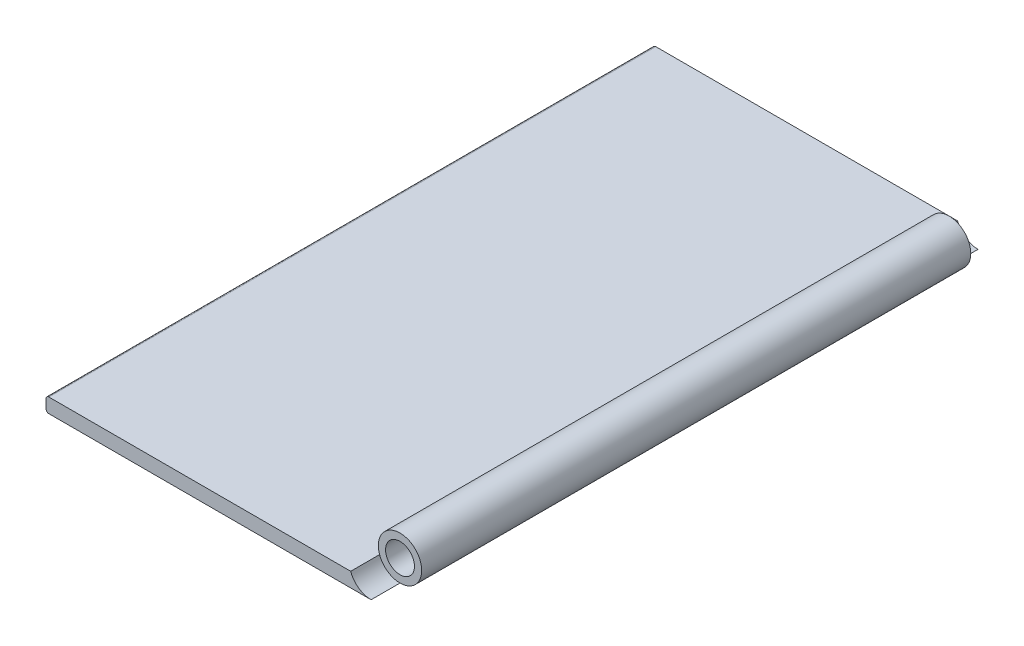
from build123d import *

# Parameters (mm, degrees)
SKETCH_1_R          = 5
EXTRUDE_1_DEPTH     = 210
SKETCH_2_R          = 7.5
CUT_EXTRUDE_1_DEPTH = 10
SKETCH_3_R          = 7.5
CUT_EXTRUDE_2_DEPTH = 10


with BuildPart() as part:
    # 草图1 → 凸台-拉伸1 (new body)
    with BuildSketch(Plane.XY):
        with BuildLine():
            Line((105.428932188, 5), (100.074072144, 5))
            Line((100.074072144, 5), (1, 5))
            ThreePointArc((1, 5), (0.292893219, 4.707106781), (0, 4))
            Line((0, 4), (0, 1))
            ThreePointArc((0, 1), (0.292893219, 0.292893219), (1, 0))
            Line((1, 0), (112.5, 0))
            ThreePointArc((112.5, 0), (116.830127019, 13.623724357), (105.428932188, 5))
        make_face()
        with Locations((112.5, 7.5)):
            Circle(SKETCH_1_R, mode=Mode.SUBTRACT)
    extrude(amount=EXTRUDE_1_DEPTH)

    # 草图2 → 切除-拉伸1 (cut)
    with BuildSketch(Plane.XY.offset(210)):
        with Locations((112.5, 7.5)):
            Circle(SKETCH_2_R)
    extrude(amount=-CUT_EXTRUDE_1_DEPTH, mode=Mode.SUBTRACT)

    # 草图3 → 切除-拉伸2 (cut)
    with BuildSketch(Plane(origin=(0, 0, 0), x_dir=(-1, 0, 0), z_dir=(0, 0, -1))):
        with Locations((-112.5, 7.5)):
            Circle(SKETCH_3_R)
    extrude(amount=-CUT_EXTRUDE_2_DEPTH, mode=Mode.SUBTRACT)


solid = part.part
